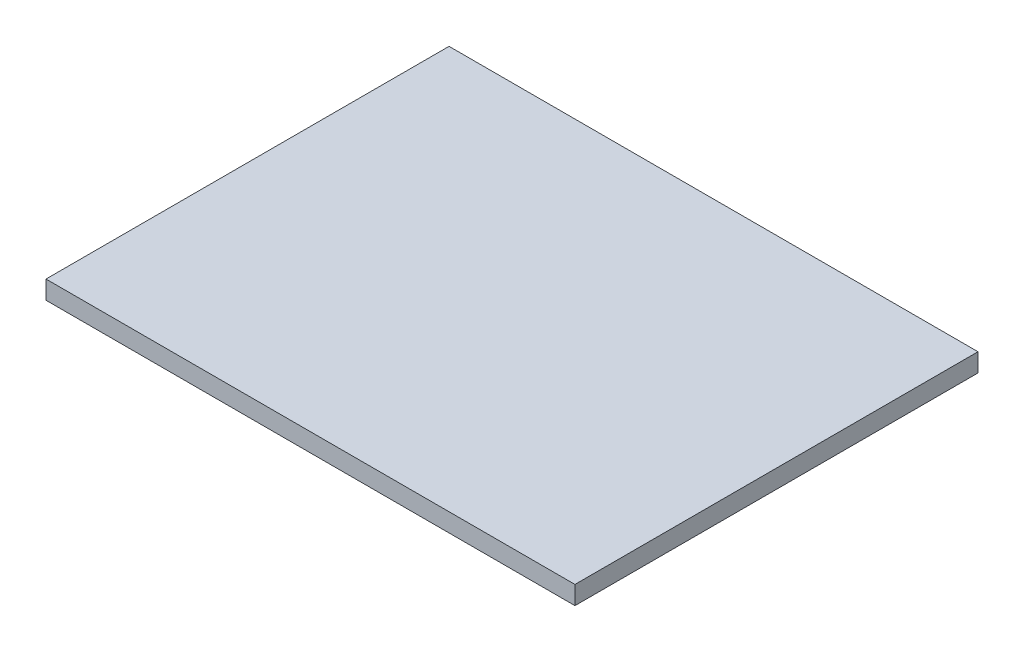
from build123d import *

# Parameters (mm, degrees)
SKETCH1_W           = 115
SKETCH1_H           = 87.625373267
BOSS_EXTRUDE1_DEPTH = 2


with BuildPart() as part:
    # Sketch1 → Boss-Extrude1 (new body, symmetric)
    with BuildSketch(Plane(origin=(0, 0, 0), x_dir=(1, 0, 0), z_dir=(0, 1, 0))):
        with Locations((57.5, -43.812686634)):
            Rectangle(SKETCH1_W, SKETCH1_H)
    extrude(amount=BOSS_EXTRUDE1_DEPTH, both=True)


solid = part.part
